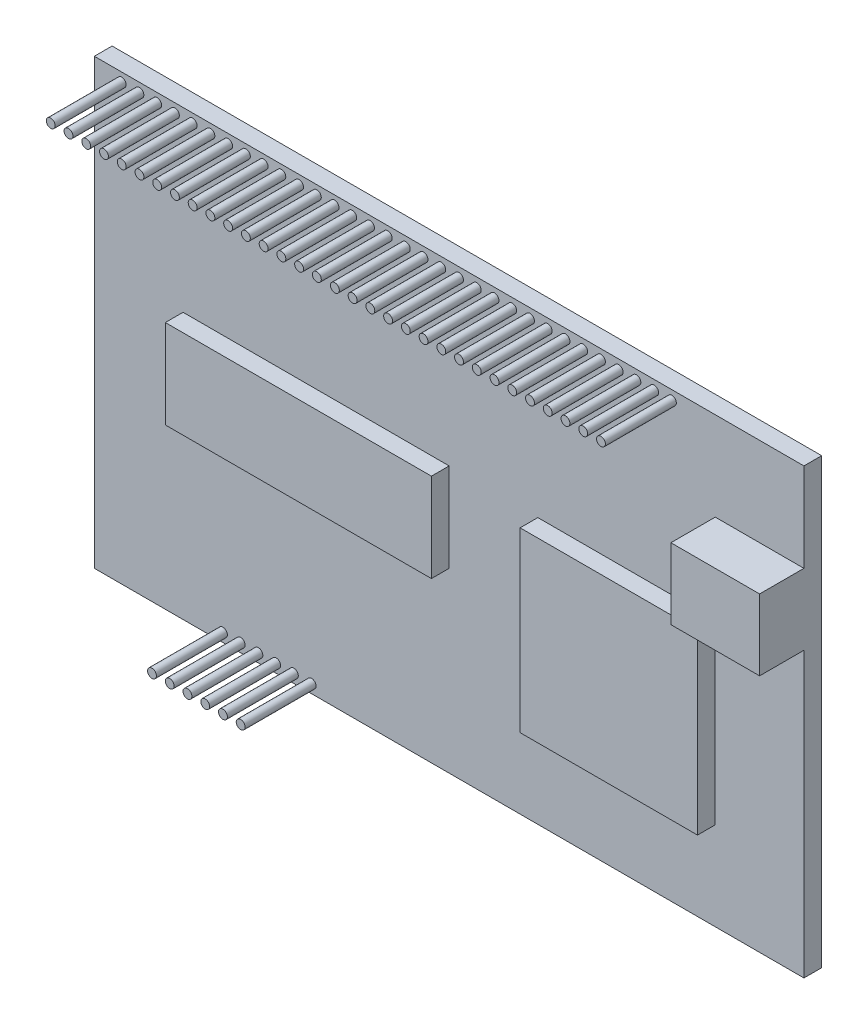
from build123d import *

# Parameters (mm, degrees)
SKETCH1_R           = 0.5
SKETCH1_W           = 30
SKETCH1_H           = 10
SKETCH1_W_2         = 20
SKETCH1_H_2         = 20
BOSS_EXTRUDE1_DEPTH = 2
SKETCH1_3_R         = 0.5
BOSS_EXTRUDE2_DEPTH = 10
SKETCH1_4_W         = 30
SKETCH1_4_H         = 10
SKETCH1_4_W_2       = 20
SKETCH1_4_H_2       = 20
BOSS_EXTRUDE3_DEPTH = 4
SKETCH1_5_W         = 10
SKETCH1_5_H         = 8
BOSS_EXTRUDE4_DEPTH = 7


with BuildPart() as part:
    # Sketch1 → Boss-Extrude1 (new body)
    with BuildSketch(Plane.XY):
        Polygon((51.15034045, 40.044862573), (-28.84965955, 40.044862573), (-28.84965955, -9.955137427), (51.15034045, -9.955137427), (51.15034045, 22.044862573), (41.15034045, 22.044862573), (41.15034045, 30.044862573), (51.15034045, 30.044862573), align=None)
        with Locations((-14.354824965, -8.955137427)):
            Circle(SKETCH1_R, mode=Mode.SUBTRACT)
        with Locations((-12.354824965, -8.955137427)):
            Circle(SKETCH1_R, mode=Mode.SUBTRACT)
        with Locations((-10.354824965, -8.955137427)):
            Circle(SKETCH1_R, mode=Mode.SUBTRACT)
        with Locations((-8.354824965, -8.955137427)):
            Circle(SKETCH1_R, mode=Mode.SUBTRACT)
        with Locations((-6.354824965, -8.955137427)):
            Circle(SKETCH1_R, mode=Mode.SUBTRACT)
        with Locations((-4.354824965, -8.955137427)):
            Circle(SKETCH1_R, mode=Mode.SUBTRACT)
        with Locations((-3.84965955, 15.044862573)):
            Rectangle(SKETCH1_W, SKETCH1_H, mode=Mode.SUBTRACT)
        with Locations((31.15034045, 10)):
            Rectangle(SKETCH1_W_2, SKETCH1_H_2, mode=Mode.SUBTRACT)
        with Locations((-25.767695538, 39.044862573)):
            Circle(SKETCH1_R, mode=Mode.SUBTRACT)
        with Locations((-23.767695538, 39.044862573)):
            Circle(SKETCH1_R, mode=Mode.SUBTRACT)
        with Locations((-21.767695538, 39.044862573)):
            Circle(SKETCH1_R, mode=Mode.SUBTRACT)
        with Locations((-19.767695538, 39.044862573)):
            Circle(SKETCH1_R, mode=Mode.SUBTRACT)
        with Locations((-17.767695538, 39.044862573)):
            Circle(SKETCH1_R, mode=Mode.SUBTRACT)
        with Locations((-15.767695538, 39.044862573)):
            Circle(SKETCH1_R, mode=Mode.SUBTRACT)
        with Locations((-13.767695538, 39.044862573)):
            Circle(SKETCH1_R, mode=Mode.SUBTRACT)
        with Locations((-11.767695538, 39.044862573)):
            Circle(SKETCH1_R, mode=Mode.SUBTRACT)
        with Locations((-9.767695538, 39.044862573)):
            Circle(SKETCH1_R, mode=Mode.SUBTRACT)
        with Locations((-7.767695538, 39.044862573)):
            Circle(SKETCH1_R, mode=Mode.SUBTRACT)
        with Locations((-5.767695538, 39.044862573)):
            Circle(SKETCH1_R, mode=Mode.SUBTRACT)
        with Locations((-3.767695538, 39.044862573)):
            Circle(SKETCH1_R, mode=Mode.SUBTRACT)
        with Locations((-1.767695538, 39.044862573)):
            Circle(SKETCH1_R, mode=Mode.SUBTRACT)
        with Locations((0.232304462, 39.044862573)):
            Circle(SKETCH1_R, mode=Mode.SUBTRACT)
        with Locations((2.232304462, 39.044862573)):
            Circle(SKETCH1_R, mode=Mode.SUBTRACT)
        with Locations((4.232304462, 39.044862573)):
            Circle(SKETCH1_R, mode=Mode.SUBTRACT)
        with Locations((6.264212791, 38.996436979)):
            Circle(SKETCH1_R, mode=Mode.SUBTRACT)
        with Locations((8.264212791, 38.996436979)):
            Circle(SKETCH1_R, mode=Mode.SUBTRACT)
        with Locations((10.264212791, 38.996436979)):
            Circle(SKETCH1_R, mode=Mode.SUBTRACT)
        with Locations((12.264212791, 38.996436979)):
            Circle(SKETCH1_R, mode=Mode.SUBTRACT)
        with Locations((14.264212791, 38.996436979)):
            Circle(SKETCH1_R, mode=Mode.SUBTRACT)
        with Locations((16.264212791, 38.996436979)):
            Circle(SKETCH1_R, mode=Mode.SUBTRACT)
        with Locations((18.264212791, 38.996436979)):
            Circle(SKETCH1_R, mode=Mode.SUBTRACT)
        with Locations((20.264212791, 38.996436979)):
            Circle(SKETCH1_R, mode=Mode.SUBTRACT)
        with Locations((22.264212791, 38.996436979)):
            Circle(SKETCH1_R, mode=Mode.SUBTRACT)
        with Locations((24.264212791, 38.996436979)):
            Circle(SKETCH1_R, mode=Mode.SUBTRACT)
        with Locations((26.264212791, 38.996436979)):
            Circle(SKETCH1_R, mode=Mode.SUBTRACT)
        with Locations((28.264212791, 38.996436979)):
            Circle(SKETCH1_R, mode=Mode.SUBTRACT)
        with Locations((30.264212791, 38.996436979)):
            Circle(SKETCH1_R, mode=Mode.SUBTRACT)
        with Locations((32.264212791, 38.996436979)):
            Circle(SKETCH1_R, mode=Mode.SUBTRACT)
        with Locations((34.264212791, 38.996436979)):
            Circle(SKETCH1_R, mode=Mode.SUBTRACT)
        with Locations((36.264212791, 38.996436979)):
            Circle(SKETCH1_R, mode=Mode.SUBTRACT)
    extrude(amount=BOSS_EXTRUDE1_DEPTH)

    # Sketch1_3 → Boss-Extrude2 (add)
    with BuildSketch(Plane.XY):
        with Locations((-25.767695538, 39.044862573)):
            Circle(SKETCH1_3_R)
        with Locations((-23.767695538, 39.044862573)):
            Circle(SKETCH1_3_R)
        with Locations((-21.767695538, 39.044862573)):
            Circle(SKETCH1_3_R)
        with Locations((-19.767695538, 39.044862573)):
            Circle(SKETCH1_3_R)
        with Locations((-17.767695538, 39.044862573)):
            Circle(SKETCH1_3_R)
        with Locations((-15.767695538, 39.044862573)):
            Circle(SKETCH1_3_R)
        with Locations((-13.767695538, 39.044862573)):
            Circle(SKETCH1_3_R)
        with Locations((-11.767695538, 39.044862573)):
            Circle(SKETCH1_3_R)
        with Locations((-14.354824965, -8.955137427)):
            Circle(SKETCH1_3_R)
        with Locations((-12.354824965, -8.955137427)):
            Circle(SKETCH1_3_R)
        with Locations((-10.354824965, -8.955137427)):
            Circle(SKETCH1_3_R)
        with Locations((-8.354824965, -8.955137427)):
            Circle(SKETCH1_3_R)
        with Locations((-6.354824965, -8.955137427)):
            Circle(SKETCH1_3_R)
        with Locations((-4.354824965, -8.955137427)):
            Circle(SKETCH1_3_R)
        with Locations((-9.767695538, 39.044862573)):
            Circle(SKETCH1_3_R)
        with Locations((-7.767695538, 39.044862573)):
            Circle(SKETCH1_3_R)
        with Locations((-5.767695538, 39.044862573)):
            Circle(SKETCH1_3_R)
        with Locations((-3.767695538, 39.044862573)):
            Circle(SKETCH1_3_R)
        with Locations((-1.767695538, 39.044862573)):
            Circle(SKETCH1_3_R)
        with Locations((0.232304462, 39.044862573)):
            Circle(SKETCH1_3_R)
        with Locations((2.232304462, 39.044862573)):
            Circle(SKETCH1_3_R)
        with Locations((4.232304462, 39.044862573)):
            Circle(SKETCH1_3_R)
        with Locations((6.264212791, 38.996436979)):
            Circle(SKETCH1_3_R)
        with Locations((8.264212791, 38.996436979)):
            Circle(SKETCH1_3_R)
        with Locations((10.264212791, 38.996436979)):
            Circle(SKETCH1_3_R)
        with Locations((12.264212791, 38.996436979)):
            Circle(SKETCH1_3_R)
        with Locations((14.264212791, 38.996436979)):
            Circle(SKETCH1_3_R)
        with Locations((16.264212791, 38.996436979)):
            Circle(SKETCH1_3_R)
        with Locations((18.264212791, 38.996436979)):
            Circle(SKETCH1_3_R)
        with Locations((20.264212791, 38.996436979)):
            Circle(SKETCH1_3_R)
        with Locations((22.264212791, 38.996436979)):
            Circle(SKETCH1_3_R)
        with Locations((24.264212791, 38.996436979)):
            Circle(SKETCH1_3_R)
        with Locations((26.264212791, 38.996436979)):
            Circle(SKETCH1_3_R)
        with Locations((28.264212791, 38.996436979)):
            Circle(SKETCH1_3_R)
        with Locations((30.264212791, 38.996436979)):
            Circle(SKETCH1_3_R)
        with Locations((32.264212791, 38.996436979)):
            Circle(SKETCH1_3_R)
        with Locations((34.264212791, 38.996436979)):
            Circle(SKETCH1_3_R)
        with Locations((36.264212791, 38.996436979)):
            Circle(SKETCH1_3_R)
    extrude(amount=BOSS_EXTRUDE2_DEPTH)

    # Sketch1_4 → Boss-Extrude3 (add)
    with BuildSketch(Plane.XY):
        with Locations((-3.84965955, 15.044862573)):
            Rectangle(SKETCH1_4_W, SKETCH1_4_H)
        with Locations((31.15034045, 10)):
            Rectangle(SKETCH1_4_W_2, SKETCH1_4_H_2)
    extrude(amount=BOSS_EXTRUDE3_DEPTH)

    # Sketch1_5 → Boss-Extrude4 (add)
    with BuildSketch(Plane.XY):
        with Locations((46.15034045, 26.044862573)):
            Rectangle(SKETCH1_5_W, SKETCH1_5_H)
    extrude(amount=BOSS_EXTRUDE4_DEPTH)


solid = part.part
